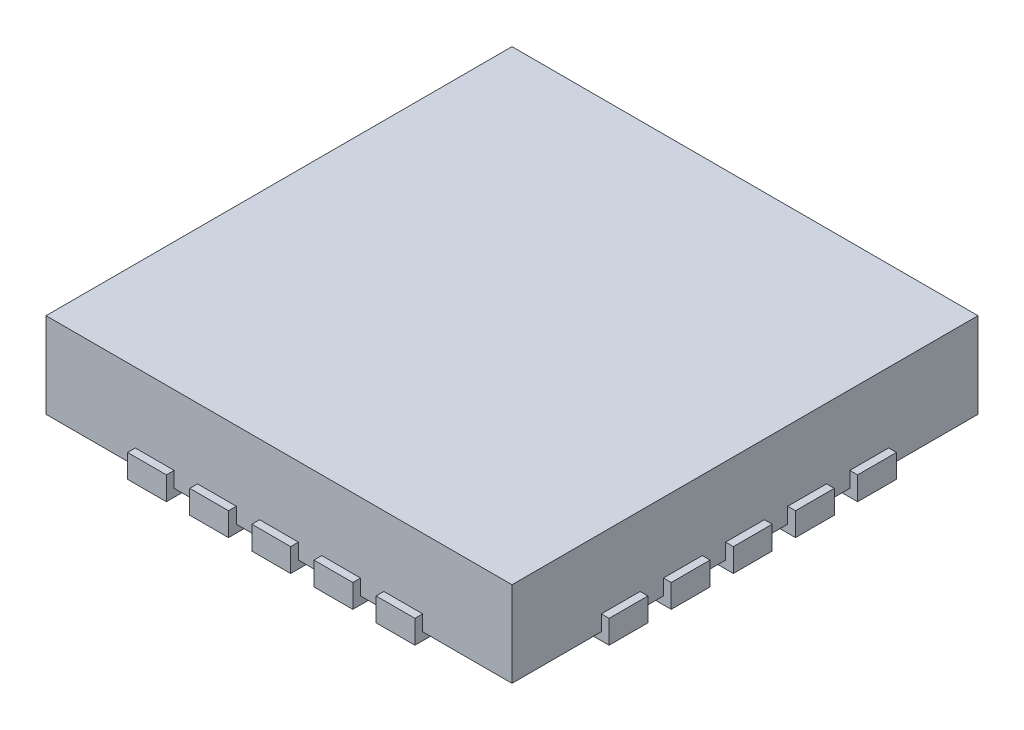
from build123d import *

# Parameters (mm, degrees)
SKETCH1_W               = 3
SKETCH1_H               = 3
BOSS_EXTRUDE1_DEPTH     = 0.55
BOSS_EXTRUDE2_DEPTH     = 0.05
SKETCH3_W               = 0.25
SKETCH3_H               = 0.15
BOSS_EXTRUDE3_DEPTH     = 0.05
MIRROR3_COPY_1_SKETCH_W = 0.25
MIRROR3_COPY_1_SKETCH_H = 0.15
MIRROR3_COPY_1_DEPTH    = 0.05
MIRROR3_COPY_2_SKETCH_W = 0.25
MIRROR3_COPY_2_SKETCH_H = 0.15
MIRROR3_COPY_2_DEPTH    = 0.05


with BuildPart() as part:
    # Sketch1 → Boss-Extrude1 (new body)
    with BuildSketch(Plane(origin=(0, 0, 0), x_dir=(1, 0, 0), z_dir=(0, 1, 0))):
        Rectangle(SKETCH1_W, SKETCH1_H)
    extrude(amount=BOSS_EXTRUDE1_DEPTH)

    # Sketch2 → Boss-Extrude2 (add)
    with BuildSketch(Plane.XZ):
        with BuildLine():
            Line((-1.115476413, -0.675), (-1.5, -0.675))
            Line((-1.5, -0.675), (-1.5, -0.925))
            Line((-1.5, -0.925), (-1.115476413, -0.925))
            ThreePointArc((-1.115476413, -0.925), (-0.990476413, -0.8), (-1.115476413, -0.675))
        make_face()
        with BuildLine():
            Line((-1.115476413, -0.275), (-1.5, -0.275))
            Line((-1.5, -0.275), (-1.5, -0.525))
            Line((-1.5, -0.525), (-1.115476413, -0.525))
            ThreePointArc((-1.115476413, -0.525), (-0.990476413, -0.4), (-1.115476413, -0.275))
        make_face()
        with BuildLine():
            Line((-1.115476413, 0.525), (-1.5, 0.525))
            Line((-1.5, 0.525), (-1.5, 0.275))
            Line((-1.5, 0.275), (-1.115476413, 0.275))
            ThreePointArc((-1.115476413, 0.275), (-0.990476413, 0.4), (-1.115476413, 0.525))
        make_face()
        with BuildLine():
            Line((-1.115476413, 0.925), (-1.5, 0.925))
            Line((-1.5, 0.925), (-1.5, 0.675))
            Line((-1.5, 0.675), (-1.115476413, 0.675))
            ThreePointArc((-1.115476413, 0.675), (-0.990476413, 0.8), (-1.115476413, 0.925))
        make_face()
        with BuildLine():
            Line((-0.675, 1.115476413), (-0.675, 1.5))
            Line((-0.675, 1.5), (-0.925, 1.5))
            Line((-0.925, 1.5), (-0.925, 1.115476413))
            ThreePointArc((-0.925, 1.115476413), (-0.8, 0.990476413), (-0.675, 1.115476413))
        make_face()
        with BuildLine():
            Line((-0.275, 1.115476413), (-0.275, 1.5))
            Line((-0.275, 1.5), (-0.525, 1.5))
            Line((-0.525, 1.5), (-0.525, 1.115476413))
            ThreePointArc((-0.525, 1.115476413), (-0.4, 0.990476413), (-0.275, 1.115476413))
        make_face()
        with BuildLine():
            Line((0.125, 1.5), (-0.125, 1.5))
            Line((-0.125, 1.5), (-0.125, 1.115476413))
            ThreePointArc((-0.125, 1.115476413), (0, 0.990476413), (0.125, 1.115476413))
            Line((0.125, 1.115476413), (0.125, 1.5))
        make_face()
        with BuildLine():
            Line((0.525, 1.5), (0.275, 1.5))
            Line((0.275, 1.5), (0.275, 1.115476413))
            ThreePointArc((0.275, 1.115476413), (0.4, 0.990476413), (0.525, 1.115476413))
            Line((0.525, 1.115476413), (0.525, 1.5))
        make_face()
        with BuildLine():
            Line((0.925, 1.5), (0.675, 1.5))
            Line((0.675, 1.5), (0.675, 1.115476413))
            ThreePointArc((0.675, 1.115476413), (0.8, 0.990476413), (0.925, 1.115476413))
            Line((0.925, 1.115476413), (0.925, 1.5))
        make_face()
        with BuildLine():
            Line((1.5, 0.675), (1.5, 0.925))
            Line((1.5, 0.925), (1.115476413, 0.925))
            ThreePointArc((1.115476413, 0.925), (0.990476413, 0.8), (1.115476413, 0.675))
            Line((1.115476413, 0.675), (1.5, 0.675))
        make_face()
        with BuildLine():
            Line((1.5, 0.275), (1.5, 0.525))
            Line((1.5, 0.525), (1.115476413, 0.525))
            ThreePointArc((1.115476413, 0.525), (0.990476413, 0.4), (1.115476413, 0.275))
            Line((1.115476413, 0.275), (1.5, 0.275))
        make_face()
        with BuildLine():
            Line((1.5, -0.125), (1.5, 0.125))
            Line((1.5, 0.125), (1.115476413, 0.125))
            ThreePointArc((1.115476413, 0.125), (0.990476413, 0), (1.115476413, -0.125))
            Line((1.115476413, -0.125), (1.5, -0.125))
        make_face()
        with BuildLine():
            Line((1.5, -0.525), (1.5, -0.275))
            Line((1.5, -0.275), (1.115476413, -0.275))
            ThreePointArc((1.115476413, -0.275), (0.990476413, -0.4), (1.115476413, -0.525))
            Line((1.115476413, -0.525), (1.5, -0.525))
        make_face()
        with BuildLine():
            Line((1.5, -0.925), (1.5, -0.675))
            Line((1.5, -0.675), (1.115476413, -0.675))
            ThreePointArc((1.115476413, -0.675), (0.990476413, -0.8), (1.115476413, -0.925))
            Line((1.115476413, -0.925), (1.5, -0.925))
        make_face()
        with BuildLine():
            Line((0.675, -1.5), (0.925, -1.5))
            Line((0.925, -1.5), (0.925, -1.115476413))
            ThreePointArc((0.925, -1.115476413), (0.8, -0.990476413), (0.675, -1.115476413))
            Line((0.675, -1.115476413), (0.675, -1.5))
        make_face()
        with BuildLine():
            Line((0.275, -1.5), (0.525, -1.5))
            Line((0.525, -1.5), (0.525, -1.115476413))
            ThreePointArc((0.525, -1.115476413), (0.4, -0.990476413), (0.275, -1.115476413))
            Line((0.275, -1.115476413), (0.275, -1.5))
        make_face()
        with BuildLine():
            Line((-0.125, -1.115476413), (-0.125, -1.5))
            Line((-0.125, -1.5), (0.125, -1.5))
            Line((0.125, -1.5), (0.125, -1.115476413))
            ThreePointArc((0.125, -1.115476413), (0, -0.990476413), (-0.125, -1.115476413))
        make_face()
        with BuildLine():
            Line((-0.525, -1.115476413), (-0.525, -1.5))
            Line((-0.525, -1.5), (-0.275, -1.5))
            Line((-0.275, -1.5), (-0.275, -1.115476413))
            ThreePointArc((-0.275, -1.115476413), (-0.4, -0.990476413), (-0.525, -1.115476413))
        make_face()
        with BuildLine():
            Line((-0.925, -1.115476413), (-0.925, -1.5))
            Line((-0.925, -1.5), (-0.675, -1.5))
            Line((-0.675, -1.5), (-0.675, -1.115476413))
            ThreePointArc((-0.675, -1.115476413), (-0.8, -0.990476413), (-0.925, -1.115476413))
        make_face()
        with BuildLine():
            Line((-1.5, -0.125), (-1.115476413, -0.125))
            ThreePointArc((-1.115476413, -0.125), (-0.990476413, 0), (-1.115476413, 0.125))
            Line((-1.115476413, 0.125), (-1.5, 0.125))
            Line((-1.5, 0.125), (-1.5, -0.125))
        make_face()
    extrude(amount=BOSS_EXTRUDE2_DEPTH)

    # Sketch3 → Boss-Extrude3 (add)
    with BuildSketch(Plane.ZY.offset(1.5)):
        with Locations((-0.8, 0.025)):
            Rectangle(SKETCH3_W, SKETCH3_H)
        with Locations((-0.4, 0.025)):
            Rectangle(SKETCH3_W, SKETCH3_H)
        with Locations((0, 0.025)):
            Rectangle(SKETCH3_W, SKETCH3_H)
        with Locations((0.4, 0.025)):
            Rectangle(SKETCH3_W, SKETCH3_H)
        with Locations((0.8, 0.025)):
            Rectangle(SKETCH3_W, SKETCH3_H)
    boss_extrude3 = extrude(amount=BOSS_EXTRUDE3_DEPTH)

    # Mirror1: Boss-Extrude3 across plane
    add(boss_extrude3.mirror(Plane.ZY))

    # Mirror2: Boss-Extrude3 across plane
    add(boss_extrude3.mirror(Plane(origin=(0, 0, 0), x_dir=(-0.707106781, 0, 0.707106781), z_dir=(0.707106781, 0, 0.707106781))))

    # Mirror3 copy 1 sketch → Mirror3 copy 1 (add)
    with BuildSketch(Plane(origin=(0, 0, -1.5), x_dir=(-1, 0, 0), z_dir=(0, 0, -1))):
        with Locations((-0.8, 0.025)):
            Rectangle(MIRROR3_COPY_1_SKETCH_W, MIRROR3_COPY_1_SKETCH_H)
        with Locations((-0.4, 0.025)):
            Rectangle(MIRROR3_COPY_1_SKETCH_W, MIRROR3_COPY_1_SKETCH_H)
        with Locations((0, 0.025)):
            Rectangle(MIRROR3_COPY_1_SKETCH_W, MIRROR3_COPY_1_SKETCH_H)
        with Locations((0.4, 0.025)):
            Rectangle(MIRROR3_COPY_1_SKETCH_W, MIRROR3_COPY_1_SKETCH_H)
        with Locations((0.8, 0.025)):
            Rectangle(MIRROR3_COPY_1_SKETCH_W, MIRROR3_COPY_1_SKETCH_H)
    extrude(amount=MIRROR3_COPY_1_DEPTH)

    # Mirror3 copy 2 sketch → Mirror3 copy 2 (add)
    with BuildSketch(Plane(origin=(-1.5, 0, 0), x_dir=(0, 0, -1), z_dir=(-1, 0, 0))):
        with Locations((-0.8, -0.025)):
            Rectangle(MIRROR3_COPY_2_SKETCH_W, MIRROR3_COPY_2_SKETCH_H)
        with Locations((-0.4, -0.025)):
            Rectangle(MIRROR3_COPY_2_SKETCH_W, MIRROR3_COPY_2_SKETCH_H)
        with Locations((0, -0.025)):
            Rectangle(MIRROR3_COPY_2_SKETCH_W, MIRROR3_COPY_2_SKETCH_H)
        with Locations((0.4, -0.025)):
            Rectangle(MIRROR3_COPY_2_SKETCH_W, MIRROR3_COPY_2_SKETCH_H)
        with Locations((0.8, -0.025)):
            Rectangle(MIRROR3_COPY_2_SKETCH_W, MIRROR3_COPY_2_SKETCH_H)
    extrude(amount=MIRROR3_COPY_2_DEPTH)


solid = part.part
